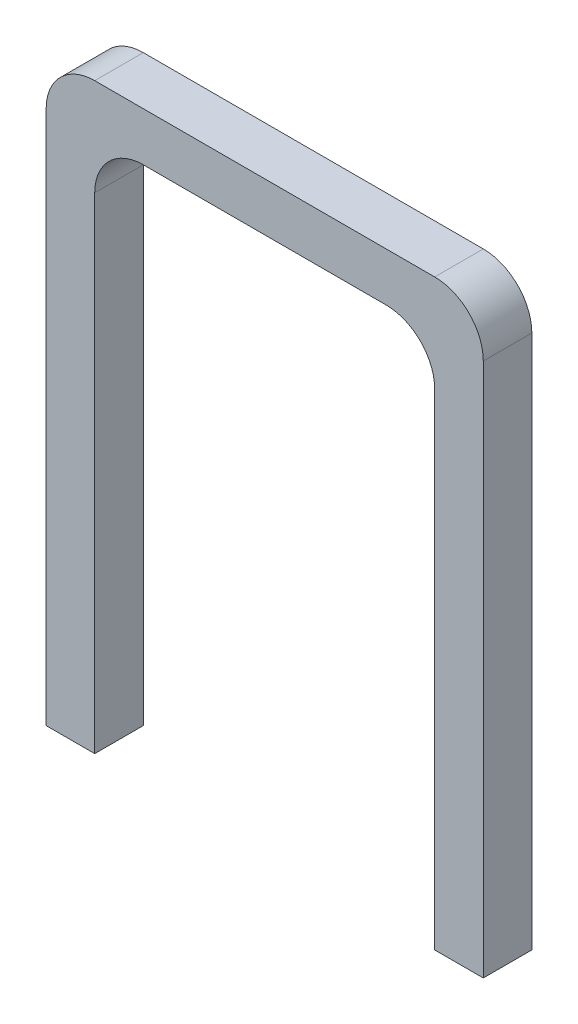
from build123d import *

# Parameters (mm, degrees)
SKETCH1_W           = 2
SKETCH1_H           = 2
BOSS_EXTRUDE1_DEPTH = 24
SKETCH2_W           = 2
SKETCH2_H           = 2
BOSS_EXTRUDE2_DEPTH = 16
SKETCH3_W           = 2
SKETCH3_H           = 2
BOSS_EXTRUDE3_DEPTH = 22
FILLET1_R           = 2
FILLET2_R           = 2


with BuildPart() as part:
    # Sketch1 → Boss-Extrude1 (new body)
    with BuildSketch(Plane(origin=(0, 0, 0), x_dir=(1, 0, 0), z_dir=(0, 1, 0))):
        with Locations((1, 1)):
            Rectangle(SKETCH1_W, SKETCH1_H)
    extrude(amount=BOSS_EXTRUDE1_DEPTH)

    # Sketch2 → Boss-Extrude2 (add)
    with BuildSketch(Plane(origin=(2, 0, 0), x_dir=(0, 0, -1), z_dir=(1, 0, 0))):
        with Locations((1, 23)):
            Rectangle(SKETCH2_W, SKETCH2_H)
    extrude(amount=BOSS_EXTRUDE2_DEPTH)

    # Sketch3 → Boss-Extrude3 (add)
    with BuildSketch(Plane(origin=(0, 22, 0), x_dir=(-1, 0, 0), z_dir=(0, -1, 0))):
        with Locations((-17, 1)):
            Rectangle(SKETCH3_W, SKETCH3_H)
    extrude(amount=BOSS_EXTRUDE3_DEPTH)

    # Fillet1
    fillet1_edges = [part.edges().sort_by_distance(p)[0] for p in [
        (2, 22, -1),
        (16, 22, -1),
    ]]
    fillet(fillet1_edges, radius=FILLET1_R)

    # Fillet2
    fillet2_edges = [part.edges().sort_by_distance(p)[0] for p in [
        (18, 24, -1),
        (0, 24, -1),
    ]]
    fillet(fillet2_edges, radius=FILLET2_R)


solid = part.part
